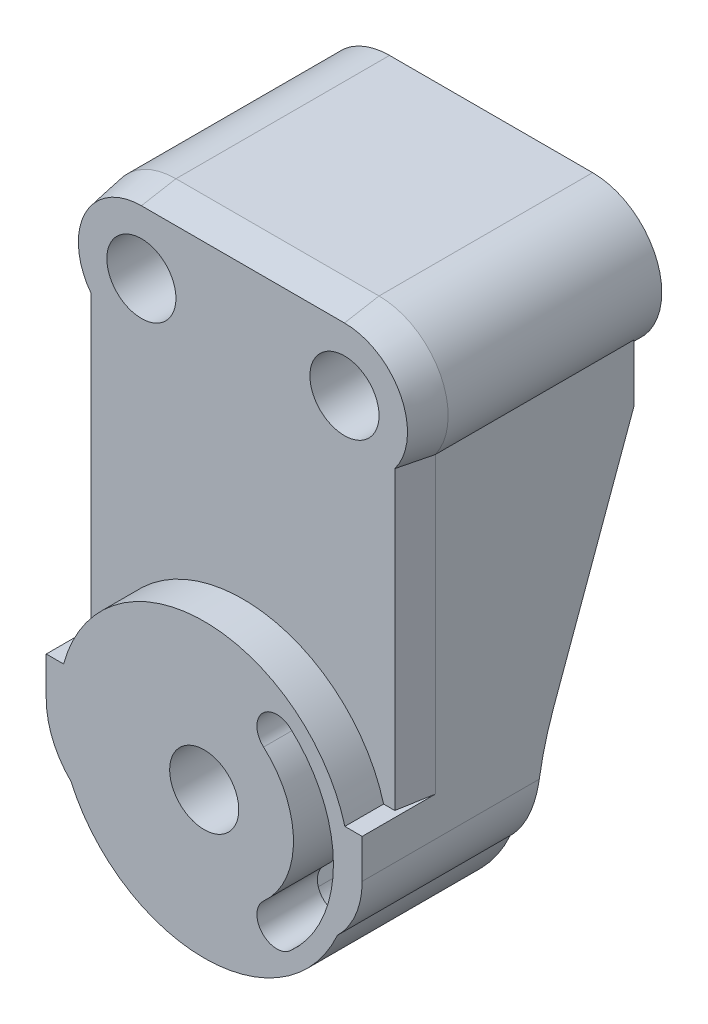
from build123d import *
from OCP.BRepFilletAPI import BRepFilletAPI_MakeChamfer

# Parameters (mm, degrees)
SKETCH39_R               = 12.7
BOSS_EXTRUDE16_DEPTH     = 105.41
CUT_EXTRUDE13_DEPTH      = 297.507996976
CUT_EXTRUDE13_DEPTH_BACK = 297.507996976
SKETCH41_R               = 12.7
BOSS_EXTRUDE17_DEPTH     = 5.461
SKETCH42_R               = 53.594
CUT_EXTRUDE14_DEPTH      = 41.91
SKETCH43_R               = 12.7
CUT_EXTRUDE15_DEPTH      = 41.275
CUT_EXTRUDE25_DEPTH      = 14.224
CHAMFER1_SIZE            = 12.7
CHAMFER1_SIZE2           = 2.239352655
CUT_EXTRUDE18_DEPTH      = 63.5
CUT_REVOLVE4_ANGLE       = 45
CUT_EXTRUDE22_REACH      = 286.32
SKETCH53_R               = 12.7
CUT_EXTRUDE23_DEPTH      = 285.32019658
CUT_EXTRUDE24_DEPTH      = 290.353535308


with BuildPart() as part:
    # Sketch39 → Boss-Extrude16 (new body)
    with BuildSketch(Plane(origin=(0, 0, 0), x_dir=(-1, 0, 0), z_dir=(0, 0, -1))):
        with BuildLine():
            Line((-37.30625, 269.9512), (37.30625, 269.9512))
            ThreePointArc((37.30625, 269.9512), (59.865817558, 256.222785651), (58.039, 229.877649733))
            Line((58.039, 229.877649733), (58.039, 107.49735517))
            ThreePointArc((58.039, 107.49735517), (55.67225609, 95.733970947), (48.940336125, 85.8012))
            ThreePointArc((48.940336125, 85.8012), (0, 54.0512), (-48.940336125, 85.8012))
            ThreePointArc((-48.940336125, 85.8012), (-55.67225609, 95.733970947), (-58.039, 107.49735517))
            Line((-58.039, 107.49735517), (-58.039, 229.877649733))
            ThreePointArc((-58.039, 229.877649733), (-59.865817558, 256.222785651), (-37.30625, 269.9512))
        make_face()
        with Locations((-37.30625, 244.5512)):
            Circle(SKETCH39_R, mode=Mode.SUBTRACT)
        with Locations((37.30625, 244.5512)):
            Circle(SKETCH39_R, mode=Mode.SUBTRACT)
    extrude(amount=BOSS_EXTRUDE16_DEPTH)

    # Sketch40 → Cut-Extrude13 (cut, two sides)
    with BuildSketch(Plane(origin=(0, 0, 0), x_dir=(0, 0, -1), z_dir=(1, 0, 0))) as cut_extrude13_sk:
        with BuildLine():
            Line((99.949, 208.9912), (70.469723816, 127.997554342))
            ThreePointArc((70.469723816, 127.997554342), (65.255767984, 108.538806271), (63.5, 88.470286378))
            Line((63.5, 88.470286378), (63.5, 54.0512))
            Line((63.5, 54.0512), (105.41, 54.0512))
            Line((105.41, 54.0512), (105.41, 229.877649733))
            Line((105.41, 229.877649733), (99.949, 229.877649733))
            Line((99.949, 229.877649733), (99.949, 208.9912))
        make_face()
    extrude(amount=CUT_EXTRUDE13_DEPTH, mode=Mode.SUBTRACT)
    extrude(cut_extrude13_sk.sketch, amount=-CUT_EXTRUDE13_DEPTH_BACK, mode=Mode.SUBTRACT)

    # Sketch41 → Boss-Extrude17 (add)
    with BuildSketch(Plane(origin=(0, 0, -105.41), x_dir=(-1, 0, 0), z_dir=(0, 0, -1))):
        with BuildLine():
            Line((-37.30625, 269.9512), (37.30625, 269.9512))
            ThreePointArc((37.30625, 269.9512), (62.70625, 244.5512), (37.30625, 219.1512))
            Line((37.30625, 219.1512), (-37.30625, 219.1512))
            ThreePointArc((-37.30625, 219.1512), (-62.70625, 244.5512), (-37.30625, 269.9512))
        make_face()
        with Locations((-37.30625, 244.5512)):
            Circle(SKETCH41_R, mode=Mode.SUBTRACT)
        with Locations((37.30625, 244.5512)):
            Circle(SKETCH41_R, mode=Mode.SUBTRACT)
    extrude(amount=-BOSS_EXTRUDE17_DEPTH)

    # Sketch42 → Cut-Extrude14 (cut)
    with BuildSketch(Plane(origin=(0, 0, -105.41), x_dir=(-1, 0, 0), z_dir=(0, 0, -1))):
        with Locations((0, 107.6452)):
            Circle(SKETCH42_R)
    extrude(amount=-CUT_EXTRUDE14_DEPTH, mode=Mode.SUBTRACT)

    # Sketch43 → Cut-Extrude15 (cut)
    with BuildSketch(Plane(origin=(0, 0, -63.5), x_dir=(-1, 0, 0), z_dir=(0, 0, -1))):
        with Locations((0, 107.6452)):
            Circle(SKETCH43_R)
        with BuildLine():
            Line((-17.140551152, 142.338453637), (-8.320140689, 124.485542452))
            ThreePointArc((-8.320140689, 124.485542452), (-8.084797468, 122.315875536), (-9.305565087, 120.50685166))
            ThreePointArc((-9.305565087, 120.50685166), (-15.875, 107.6452), (-9.305565087, 94.78354834))
            ThreePointArc((-9.305565087, 94.78354834), (-8.084797468, 92.974524464), (-8.320140689, 90.804857548))
            Line((-8.320140689, 90.804857548), (-17.140551152, 72.951946363))
            ThreePointArc((-17.140551152, 72.951946363), (-24.663775135, 67.208970871), (-33.791061651, 69.713628025))
            ThreePointArc((-33.791061651, 69.713628025), (-50.8, 107.6452), (-33.791061651, 145.576771975))
            ThreePointArc((-33.791061651, 145.576771975), (-24.663775135, 148.081429129), (-17.140551152, 142.338453637))
        make_face()
    extrude(amount=-CUT_EXTRUDE15_DEPTH, mode=Mode.SUBTRACT)

    # Sketch57 → Cut-Extrude25 (cut)
    with BuildSketch(Plane.XY):
        with BuildLine():
            Line((-58.039, 121.8184), (-51.685948165, 121.8184))
            ThreePointArc((-51.685948165, 121.8184), (0, 161.2392), (51.685948165, 121.8184))
            Line((51.685948165, 121.8184), (58.039, 121.8184))
            Line((58.039, 121.8184), (58.039, 229.877649733))
            ThreePointArc((58.039, 229.877649733), (59.865817558, 256.222785651), (37.30625, 269.9512))
            Line((37.30625, 269.9512), (-37.30625, 269.9512))
            ThreePointArc((-37.30625, 269.9512), (-59.865817558, 256.222785651), (-58.039, 229.877649733))
            Line((-58.039, 229.877649733), (-58.039, 121.8184))
        make_face()
    extrude(amount=-CUT_EXTRUDE25_DEPTH, mode=Mode.SUBTRACT)

    # Chamfer1: one chamfer whose edges measure the first distance from different faces: ONE call of the kernel's chamfer builder (chamfer() names one face for all edges)
    chamfer1_edges_1 = [part.edges().sort_by_distance(p)[0] for p in [
        (58.039, 175.848024867, -14.224),
    ]]
    chamfer1_side_1 = [part.faces().sort_by_distance(p)[0] for p in [
        (58.039, 173.156318685, -49.465514594),
    ]]
    chamfer1_edges_2 = [part.edges().sort_by_distance(p)[0] for p in [
        (-58.039, 175.848024867, -14.224),
    ]]
    chamfer1_side_2 = [part.faces().sort_by_distance(p)[0] for p in [
        (-58.039, 173.156318685, -49.465514594),
    ]]
    chamfer1_edges_3 = [part.edges().sort_by_distance(p)[0] for p in [
        (-59.865817558, 256.222785651, -14.224),
    ]]
    chamfer1_side_3 = [part.faces().sort_by_distance(p)[0] for p in [
        (-59.865817558, 256.222785651, -57.0865),
    ]]
    chamfer1_edges_4 = [part.edges().sort_by_distance(p)[0] for p in [
        (0, 269.9512, -14.224),
    ]]
    chamfer1_side_4 = [part.faces().sort_by_distance(p)[0] for p in [
        (0, 269.9512, -57.0865),
    ]]
    chamfer1_edges_5 = [part.edges().sort_by_distance(p)[0] for p in [
        (59.865817558, 256.222785651, -14.224),
    ]]
    chamfer1_side_5 = [part.faces().sort_by_distance(p)[0] for p in [
        (59.865817558, 256.222785651, -57.0865),
    ]]
    chamfer1 = BRepFilletAPI_MakeChamfer(part.part.solid().wrapped)
    for e in chamfer1_edges_1:
        chamfer1.Add(CHAMFER1_SIZE, CHAMFER1_SIZE2, e.wrapped, chamfer1_side_1[0].wrapped)  # the first distance lies on this face
    for e in chamfer1_edges_2:
        chamfer1.Add(CHAMFER1_SIZE, CHAMFER1_SIZE2, e.wrapped, chamfer1_side_2[0].wrapped)  # the first distance lies on this face
    for e in chamfer1_edges_3:
        chamfer1.Add(CHAMFER1_SIZE, CHAMFER1_SIZE2, e.wrapped, chamfer1_side_3[0].wrapped)  # the first distance lies on this face
    for e in chamfer1_edges_4:
        chamfer1.Add(CHAMFER1_SIZE, CHAMFER1_SIZE2, e.wrapped, chamfer1_side_4[0].wrapped)  # the first distance lies on this face
    for e in chamfer1_edges_5:
        chamfer1.Add(CHAMFER1_SIZE, CHAMFER1_SIZE2, e.wrapped, chamfer1_side_5[0].wrapped)  # the first distance lies on this face
    add(Compound.cast(chamfer1.Shape()), mode=Mode.REPLACE)

    # Sketch46 → Cut-Extrude18 (cut)
    with BuildSketch(Plane(origin=(0, 0, -105.41), x_dir=(-1, 0, 0), z_dir=(0, 0, -1))):
        with BuildLine():
            Line((-56.154391463, 206.4512), (-56.154391463, 123.5202))
            Line((-56.154391463, 123.5202), (-51.188877806, 123.5202))
            ThreePointArc((-51.188877806, 123.5202), (-38.080986117, 145.35667481), (-16.37335621, 158.676857257))
            ThreePointArc((-16.37335621, 158.676857257), (-16.447164367, 159.694072309), (-16.088636924, 160.64886662))
            Line((-16.088636924, 160.64886662), (-32.030251423, 219.1512))
            Line((-32.030251423, 219.1512), (-49.871677642, 219.1512))
            Line((-49.871677642, 219.1512), (-56.154391463, 206.4512))
        make_face()
        with BuildLine():
            Line((56.154391463, 206.4512), (56.154391463, 123.5202))
            Line((56.154391463, 123.5202), (51.188877806, 123.5202))
            ThreePointArc((51.188877806, 123.5202), (38.083220696, 145.354418203), (16.379403996, 158.674916448))
            ThreePointArc((16.379403996, 158.674916448), (16.453052349, 159.697717152), (16.090874379, 160.657077605))
            Line((16.090874379, 160.657077605), (32.030251423, 219.1512))
            Line((32.030251423, 219.1512), (49.871677642, 219.1512))
            Line((49.871677642, 219.1512), (56.154391463, 206.4512))
        make_face()
        with BuildLine():
            Line((28.739484198, 219.1512), (13.027568982, 161.491814117))
            ThreePointArc((13.027568982, 161.491814117), (12.22875634, 160.848818221), (11.773335802, 159.930048667))
            ThreePointArc((11.773335802, 159.930048667), (-0.003175786, 161.239199906), (-11.77953214, 159.928653009))
            ThreePointArc((-11.77953214, 159.928653009), (-12.231981249, 160.842690157), (-13.025331527, 161.483603132))
            Line((-13.025331527, 161.483603132), (-28.739484198, 219.1512))
            Line((-28.739484198, 219.1512), (28.739484198, 219.1512))
        make_face()
    extrude(amount=-CUT_EXTRUDE18_DEPTH, mode=Mode.SUBTRACT)

    # Sketch47 → Cut-Revolve4 (revolve, symmetric, cut)
    with BuildSketch(Plane(origin=(0, 0, 0), x_dir=(0, 0, -1), z_dir=(1, 0, 0))) as cut_revolve4_sk:
        Polygon((99.949, 219.1512), (63.5, 161.085477364), (105.41, 161.085477364), (105.41, 219.1512), align=None)
    revolve(axis=Axis((0, 107.110477364, -63.5), (0, 0, -1)), revolution_arc=CUT_REVOLVE4_ANGLE / 2, mode=Mode.SUBTRACT)
    revolve(cut_revolve4_sk.sketch, axis=Axis((0, 107.110477364, -63.5), (0, 0, 1)), revolution_arc=CUT_REVOLVE4_ANGLE / 2, mode=Mode.SUBTRACT)

    # Sketch52 → Cut-Extrude22 (cut, up to next)
    with BuildSketch(Plane(origin=(0, 0, -63.5), x_dir=(-1, 0, 0), z_dir=(0, 0, -1)), mode=Mode.PRIVATE) as cut_extrude22_sk1:
        with BuildLine():
            Line((-56.154391463, 123.5202), (-51.188877806, 123.5202))
            ThreePointArc((-51.188877806, 123.5202), (-53.59155752, 107.133537422), (-50.876442713, 90.795736718))
            ThreePointArc((-50.876442713, 90.795736718), (-54.826433246, 106.946521771), (-56.154391463, 123.5202))
        make_face()
    cut_extrude22_tool1 = extrude(cut_extrude22_sk1.sketch, amount=CUT_EXTRUDE22_REACH, mode=Mode.PRIVATE) & part.part
    # Sketch52 → Cut-Extrude22 (cut, up to next)
    with BuildSketch(Plane(origin=(0, 0, -63.5), x_dir=(-1, 0, 0), z_dir=(0, 0, -1)), mode=Mode.PRIVATE) as cut_extrude22_sk2:
        with BuildLine():
            Line((51.188877806, 123.5202), (56.154391463, 123.5202))
            ThreePointArc((56.154391463, 123.5202), (54.826433246, 106.946521771), (50.876442713, 90.795736718))
            ThreePointArc((50.876442713, 90.795736718), (53.59155752, 107.133537422), (51.188877806, 123.5202))
        make_face()
    cut_extrude22_tool2 = extrude(cut_extrude22_sk2.sketch, amount=CUT_EXTRUDE22_REACH, mode=Mode.PRIVATE) & part.part
    add(cut_extrude22_tool1.solids().sort_by_distance((54.141808, 115.249163, -63.5))[0], mode=Mode.SUBTRACT)
    add(cut_extrude22_tool2.solids().sort_by_distance((-54.141808, 115.249163, -63.5))[0], mode=Mode.SUBTRACT)

    # Sketch53 → Cut-Extrude23 (cut, through all)
    with BuildSketch(Plane(origin=(0, 0, -63.5), x_dir=(-1, 0, 0), z_dir=(0, 0, -1))):
        with Locations((0, 107.6452)):
            Circle(SKETCH53_R)
    extrude(amount=-CUT_EXTRUDE23_DEPTH, mode=Mode.SUBTRACT)

    # Sketch54 → Cut-Extrude24 (cut, through all)
    with BuildSketch(Plane(origin=(0, 0, -22.225), x_dir=(-1, 0, 0), z_dir=(0, 0, -1))):
        with BuildLine():
            ThreePointArc((-31.581997064, 143.09702472), (-47.47898919, 107.6452), (-31.581997064, 72.19337528))
            ThreePointArc((-31.581997064, 72.19337528), (-21.218076505, 72.791679022), (-21.816380247, 83.155599581))
            ThreePointArc((-21.816380247, 83.155599581), (-32.79778919, 107.6452), (-21.816380247, 132.134800419))
            ThreePointArc((-21.816380247, 132.134800419), (-21.218076505, 142.498720978), (-31.581997064, 143.09702472))
        make_face()
    extrude(amount=-CUT_EXTRUDE24_DEPTH, mode=Mode.SUBTRACT)


solid = part.part
